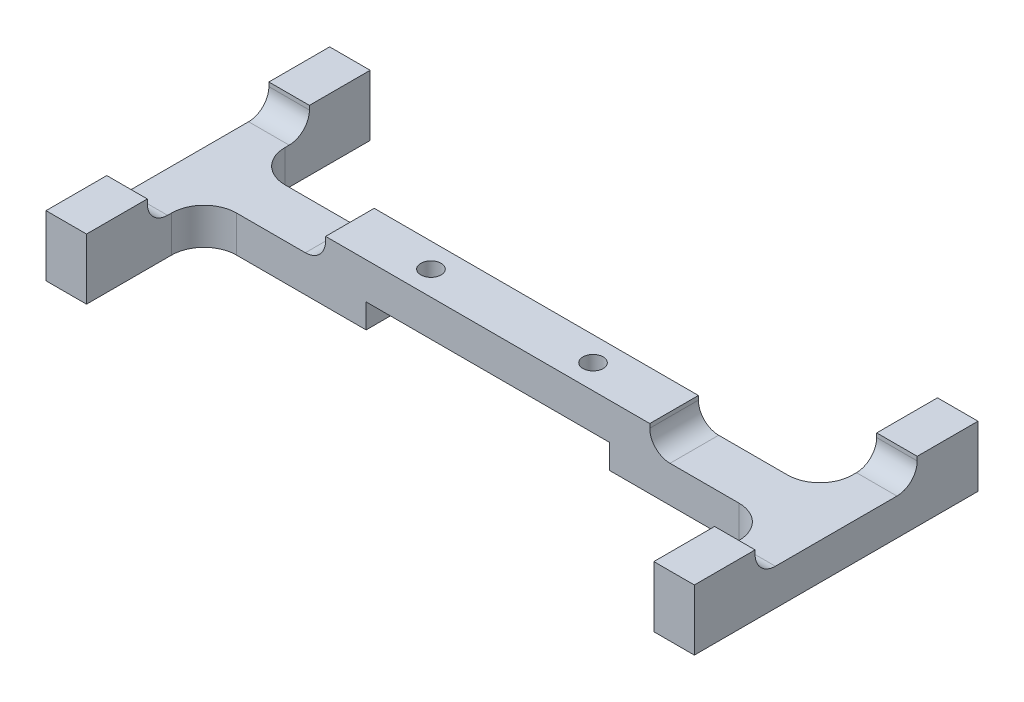
from build123d import *

# Parameters (mm, degrees)
SKETCH1_W           = 101.6
SKETCH1_H           = 44.45
BOSS_EXTRUDE1_DEPTH = 9.525
SKETCH2_W           = 88.9
SKETCH2_H           = 18.415
CUT_EXTRUDE1_DEPTH  = 10.525
FILLET1_R           = 5.08
SKETCH3_W           = 25.4
SKETCH3_H           = 25.4
CUT_EXTRUDE2_DEPTH  = 3.81
FILLET2_R           = 3.175
SKETCH4_R           = 1.5875
CUT_EXTRUDE3_DEPTH  = 10.525
SKETCH5_W           = 38.1
SKETCH5_H           = 7.62
CUT_EXTRUDE4_DEPTH  = 3.81


with BuildPart() as part:
    # Sketch1 → Boss-Extrude1 (new body)
    with BuildSketch(Plane(origin=(0, 0, 0), x_dir=(1, 0, 0), z_dir=(0, 1, 0))):
        Rectangle(SKETCH1_W, SKETCH1_H)
    extrude(amount=BOSS_EXTRUDE1_DEPTH)

    # Sketch2 → Cut-Extrude1 (cut, through all)
    with BuildSketch(Plane(origin=(0, 9.525, 0), x_dir=(1, 0, 0), z_dir=(0, 1, 0))):
        with Locations((0, -13.0175)):
            Rectangle(SKETCH2_W, SKETCH2_H)
    cut_extrude1 = extrude(amount=-CUT_EXTRUDE1_DEPTH, mode=Mode.SUBTRACT)

    # Mirror1: Cut-Extrude1 across plane
    add(cut_extrude1.mirror(Plane.XY), mode=Mode.SUBTRACT)

    # Fillet1
    fillet1_edges = [part.edges().sort_by_distance(p)[0] for p in [
        (-44.45, 4.7625, 3.81),
        (44.45, 4.7625, 3.81),
        (-44.45, 4.7625, -3.81),
        (44.45, 4.7625, -3.81),
    ]]
    fillet(fillet1_edges, radius=FILLET1_R)

    # Sketch3 → Cut-Extrude2 (cut)
    with BuildSketch(Plane(origin=(0, 9.525, 0), x_dir=(1, 0, 0), z_dir=(0, 1, 0))):
        with Locations((-38.1, 0)):
            Rectangle(SKETCH3_W, SKETCH3_H)
    cut_extrude2 = extrude(amount=-CUT_EXTRUDE2_DEPTH, mode=Mode.SUBTRACT)

    # Mirror2: Cut-Extrude2 across plane
    add(cut_extrude2.mirror(Plane(origin=(0, 0, 0), x_dir=(0, 0, 1), z_dir=(1, 0, 0))), mode=Mode.SUBTRACT)

    # Fillet2
    fillet2_edges = [part.edges().sort_by_distance(p)[0] for p in [
        (47.625, 5.715, -12.7),
        (47.625, 5.715, 12.7),
        (25.4, 5.715, 0),
        (-47.625, 5.715, 12.7),
        (-25.4, 5.715, 0),
        (-47.625, 5.715, -12.7),
    ]]
    fillet(fillet2_edges, radius=FILLET2_R)

    # Sketch4 → Cut-Extrude3 (cut, through all)
    with BuildSketch(Plane.XZ):
        with Locations((-12.7, 0)):
            Circle(SKETCH4_R)
    cut_extrude3 = extrude(amount=-CUT_EXTRUDE3_DEPTH, mode=Mode.SUBTRACT)

    # Sketch5 → Cut-Extrude4 (cut)
    with BuildSketch(Plane.XZ):
        Rectangle(SKETCH5_W, SKETCH5_H)
    extrude(amount=-CUT_EXTRUDE4_DEPTH, mode=Mode.SUBTRACT)

    # Mirror3: Cut-Extrude3 across plane
    add(cut_extrude3.mirror(Plane(origin=(0, 0, 0), x_dir=(0, 0, 1), z_dir=(1, 0, 0))), mode=Mode.SUBTRACT)


solid = part.part
